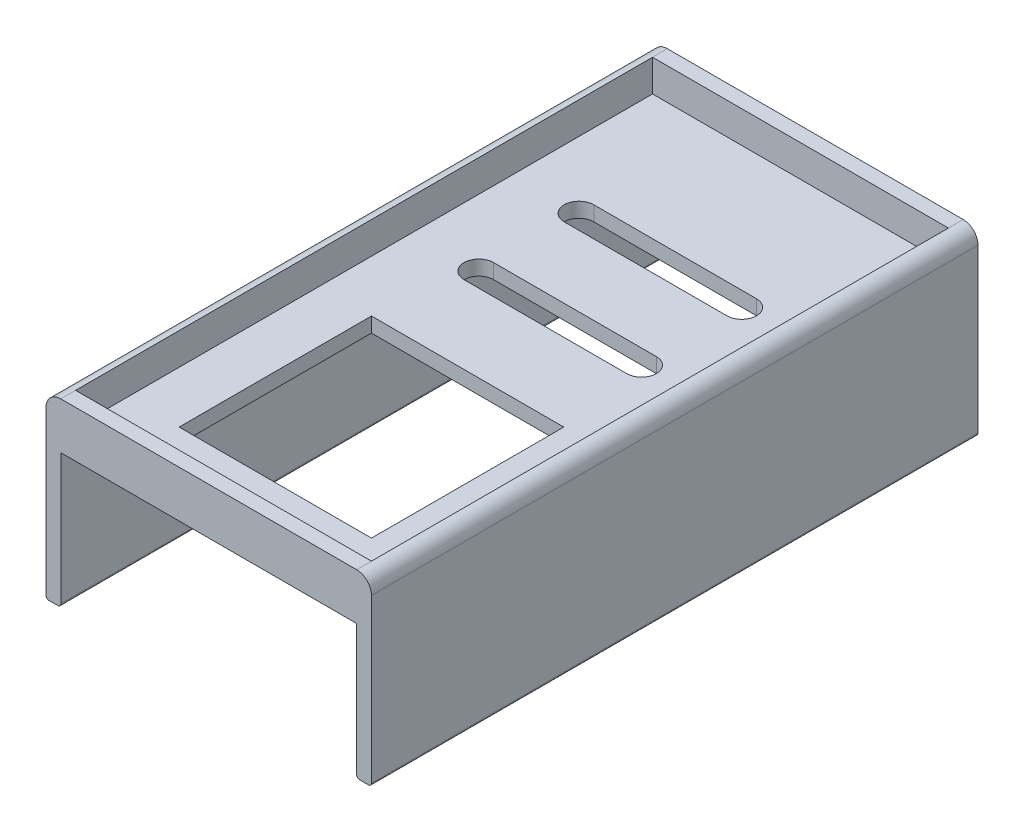
from build123d import *

# Parameters (mm, degrees)
BOSS_EXTRUDE1_DEPTH = 410
SKETCH4_W           = 200
SKETCH4_H           = 390
CUT_EXTRUDE1_DEPTH  = 21.5
SKETCH5_W           = 130
SKETCH5_H           = 130
CUT_EXTRUDE2_DEPTH  = 30
SKETCH9_W           = 10
SKETCH9_H           = 410
BOSS_EXTRUDE2_DEPTH = 2
SKETCH10_W          = 10
SKETCH10_H          = 410
BOSS_EXTRUDE3_DEPTH = 2
CUT_EXTRUDE4_DEPTH  = 600


with BuildPart() as part:
    # Sketch3 → Boss-Extrude1 (new body)
    with BuildSketch(Plane.XY):
        Polygon((-76.099744246, 40.652173913), (143.900255754, 40.652173913), (143.900255754, -79.347826087), (133.900255754, -79.347826087), (133.900255754, 9.152173913), (-66.099744246, 9.152173913), (-66.099744246, -79.347826087), (-76.099744246, -79.347826087), align=None)
    extrude(amount=-BOSS_EXTRUDE1_DEPTH)

    # Sketch4 → Cut-Extrude1 (cut)
    with BuildSketch(Plane(origin=(0, 40.652173913, 0), x_dir=(1, 0, 0), z_dir=(0, 1, 0))):
        with Locations((33.900255754, 205)):
            Rectangle(SKETCH4_W, SKETCH4_H)
    extrude(amount=-CUT_EXTRUDE1_DEPTH, mode=Mode.SUBTRACT)

    # Sketch5 → Cut-Extrude2 (cut)
    with BuildSketch(Plane(origin=(0, 19.152173913, 0), x_dir=(1, 0, 0), z_dir=(0, 1, 0))):
        with Locations((33.900255754, 110)):
            Rectangle(SKETCH5_W, SKETCH5_H)
        with BuildLine():
            Line((-21.099744246, 247.552781264), (88.900255754, 247.552781264))
            ThreePointArc((88.900255754, 247.552781264), (98.900255754, 237.552781264), (88.900255754, 227.552781264))
            Line((88.900255754, 227.552781264), (-21.099744246, 227.552781264))
            ThreePointArc((-21.099744246, 227.552781264), (-31.099744246, 237.552781264), (-21.099744246, 247.552781264))
        make_face()
        with BuildLine():
            Line((-21.099744246, 315.266550997), (88.900255754, 315.266550997))
            ThreePointArc((88.900255754, 315.266550997), (98.900255754, 305.266550997), (88.900255754, 295.266550997))
            Line((88.900255754, 295.266550997), (-21.099744246, 295.266550997))
            ThreePointArc((-21.099744246, 295.266550997), (-31.099744246, 305.266550997), (-21.099744246, 315.266550997))
        make_face()
    extrude(amount=-CUT_EXTRUDE2_DEPTH, mode=Mode.SUBTRACT)

    # Sketch9 → Boss-Extrude2 (add)
    with BuildSketch(Plane.XZ.offset(79.347826087)):
        with Locations((138.900255754, -205)):
            Rectangle(SKETCH9_W, SKETCH9_H)
    extrude(amount=BOSS_EXTRUDE2_DEPTH)

    # Sketch10 → Boss-Extrude3 (add)
    with BuildSketch(Plane.XZ.offset(79.347826087)):
        with Locations((-71.099744246, -205)):
            Rectangle(SKETCH10_W, SKETCH10_H)
    extrude(amount=BOSS_EXTRUDE3_DEPTH)

    # Sketch11 → Cut-Extrude4 (cut)
    with BuildSketch(Plane.XY):
        with BuildLine():
            Line((-76.099744246, 40.652173913), (-76.099744246, 30.652173913))
            ThreePointArc((-76.099744246, 30.652173913), (-73.170812057, 37.723241725), (-66.099744246, 40.652173913))
            Line((-66.099744246, 40.652173913), (-76.099744246, 40.652173913))
        make_face()
        with BuildLine():
            Line((143.900255754, 40.652173913), (133.900255754, 40.652173913))
            ThreePointArc((133.900255754, 40.652173913), (140.971323566, 37.723241725), (143.900255754, 30.652173913))
            Line((143.900255754, 30.652173913), (143.900255754, 40.652173913))
        make_face()
        with BuildLine():
            Line((143.900255754, -81.347826087), (143.900255754, -79.347826087))
            ThreePointArc((143.900255754, -79.347826087), (143.314469317, -80.762039649), (141.900255754, -81.347826087))
            Line((141.900255754, -81.347826087), (143.900255754, -81.347826087))
        make_face()
        with BuildLine():
            Line((133.900255754, -81.347826087), (135.900255754, -81.347826087))
            ThreePointArc((135.900255754, -81.347826087), (134.486042192, -80.762039649), (133.900255754, -79.347826087))
            Line((133.900255754, -79.347826087), (133.900255754, -81.347826087))
        make_face()
        with BuildLine():
            ThreePointArc((-74.099744246, -81.347826087), (-75.513957808, -80.762039649), (-76.099744246, -79.347826087))
            Line((-76.099744246, -79.347826087), (-76.099744246, -81.347826087))
            Line((-76.099744246, -81.347826087), (-74.099744246, -81.347826087))
        make_face()
        with BuildLine():
            ThreePointArc((-66.099744246, -79.347826087), (-66.685530683, -80.762039649), (-68.099744246, -81.347826087))
            Line((-68.099744246, -81.347826087), (-66.099744246, -81.347826087))
            Line((-66.099744246, -81.347826087), (-66.099744246, -79.347826087))
        make_face()
    extrude(amount=-CUT_EXTRUDE4_DEPTH, mode=Mode.SUBTRACT)


solid = part.part
